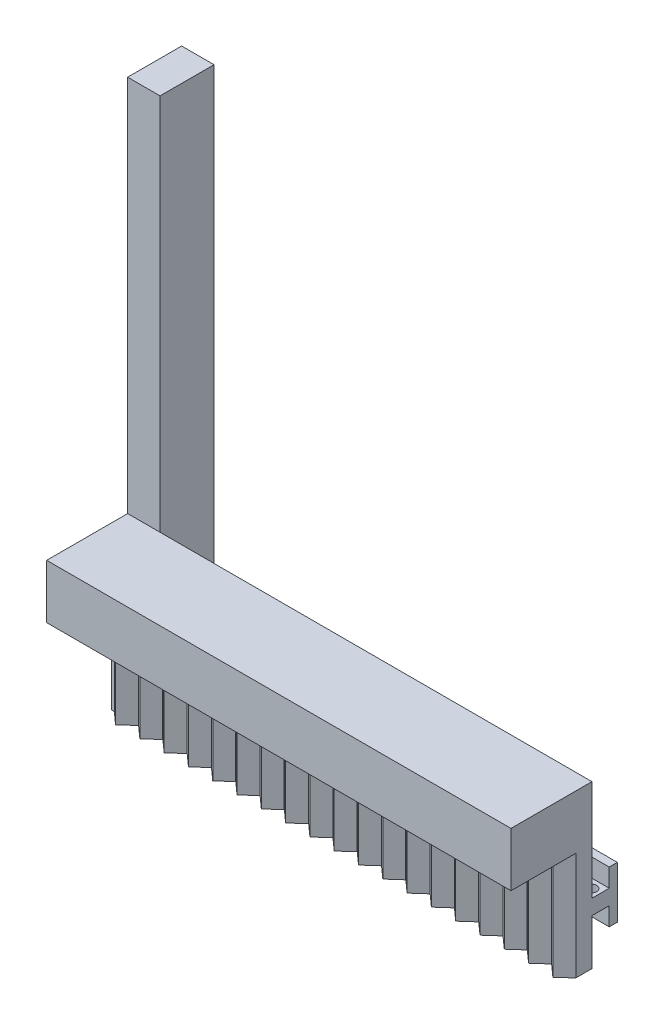
from build123d import *

# Parameters (mm, degrees)
SKETCH4_W           = 6
SKETCH4_H           = 100
BOSS_EXTRUDE2_DEPTH = 10
BOSS_EXTRUDE3_DEPTH = 80
SKETCH6_W           = 86
SKETCH6_H           = 20
BOSS_EXTRUDE4_DEPTH = 3
SKETCH7_R           = 1.026650489
CUT_EXTRUDE2_DEPTH  = 10
BOSS_EXTRUDE6_DEPTH = 20
CUT_EXTRUDE3_DEPTH  = 10
SKETCH11_W          = 86
SKETCH11_H          = 10
BOSS_EXTRUDE7_DEPTH = 15


with BuildPart() as part:
    # Sketch4 → Boss-Extrude2 (new body)
    with BuildSketch(Plane.XY):
        with Locations((-3, 5.941704036)):
            Rectangle(SKETCH4_W, SKETCH4_H)
    extrude(amount=BOSS_EXTRUDE2_DEPTH)

    # Sketch5 → Boss-Extrude3 (add)
    with BuildSketch(Plane(origin=(0, 0, 0), x_dir=(0, 0, -1), z_dir=(1, 0, 0))):
        Polygon((-10, -32.758295964), (-6.8, -32.758295964), (-6.8, -29.358295964), (-5.3, -29.358295964), (-5.3, -38.958295964), (-6.8, -38.958295964), (-6.8, -35.558295964), (-10, -35.558295964), align=None)
    extrude(amount=BOSS_EXTRUDE3_DEPTH)

    # Sketch6 → Boss-Extrude4 (add)
    with BuildSketch(Plane.XY.offset(10)):
        with Locations((37, -34.058295964)):
            Rectangle(SKETCH6_W, SKETCH6_H)
    extrude(amount=BOSS_EXTRUDE4_DEPTH)

    # Sketch7 → Cut-Extrude2 (cut)
    with BuildSketch(Plane(origin=(0, -35.558295964, 0), x_dir=(-1, 0, 0), z_dir=(0, -1, 0))):
        with Locations((-78.362195551, -8.533372311)):
            Circle(SKETCH7_R)
    extrude(amount=-CUT_EXTRUDE2_DEPTH, mode=Mode.SUBTRACT)

    # Sketch8 → Boss-Extrude6 (add)
    with BuildSketch(Plane(origin=(0, -24.058295964, 0), x_dir=(1, 0, 0), z_dir=(0, 1, 0))):
        Polygon((80, -13), (77.763932023, -15), (75.527864045, -13), align=None)
        Polygon((75.5, -13), (73.263932023, -15), (71.027864045, -13), align=None)
        Polygon((71, -13), (68.763932023, -15), (66.527864045, -13), align=None)
        Polygon((66.5, -13), (64.263932023, -15), (62.027864045, -13), align=None)
        Polygon((62, -13), (59.763932023, -15), (57.527864045, -13), align=None)
        Polygon((57.5, -13), (55.263932023, -15), (53.027864045, -13), align=None)
        Polygon((53, -13), (50.763932023, -15), (48.527864045, -13), align=None)
        Polygon((48.5, -13), (46.263932023, -15), (44.027864045, -13), align=None)
        Polygon((44, -13), (41.763932023, -15), (39.527864045, -13), align=None)
        Polygon((39.5, -13), (37.263932023, -15), (35.027864045, -13), align=None)
        Polygon((35, -13), (32.763932023, -15), (30.527864045, -13), align=None)
        Polygon((30.5, -13), (28.263932023, -15), (26.027864045, -13), align=None)
        Polygon((26, -13), (23.763932023, -15), (21.527864045, -13), align=None)
        Polygon((21.5, -13), (19.263932023, -15), (17.027864045, -13), align=None)
        Polygon((17, -13), (14.763932023, -15), (12.527864045, -13), align=None)
        Polygon((12.5, -13), (10.263932023, -15), (8.027864045, -13), align=None)
        Polygon((8, -13), (5.763932023, -15), (3.527864045, -13), align=None)
        Polygon((3.5, -13), (1.263932023, -15), (-0.972135955, -13), align=None)
        Polygon((-1, -13), (-3.236067977, -15), (-5.472135955, -13), align=None)
    extrude(amount=-BOSS_EXTRUDE6_DEPTH)

    # Sketch9 → Cut-Extrude3 (cut)
    with BuildSketch(Plane(origin=(0, 0, 0), x_dir=(0, 0, -1), z_dir=(1, 0, 0))):
        Polygon((-10, -24.058295964), (3.159373841, -24.058295964), (3.159373841, -44.058295964), (-10, -44.058295964), (-10, -35.558295964), (-6.8, -35.558295964), (-6.8, -39.06749372), (-5.2003516, -39.06749372), (-5.2003516, -29.455913505), (-6.8, -29.455913505), (-6.8, -32.758295964), (-10, -32.758295964), align=None)
    extrude(amount=-CUT_EXTRUDE3_DEPTH, mode=Mode.SUBTRACT)

    # Sketch11 → Boss-Extrude7 (add)
    with BuildSketch(Plane.XY.offset(10)):
        with Locations((37, -19.058295964)):
            Rectangle(SKETCH11_W, SKETCH11_H)
    extrude(amount=BOSS_EXTRUDE7_DEPTH)


solid = part.part
